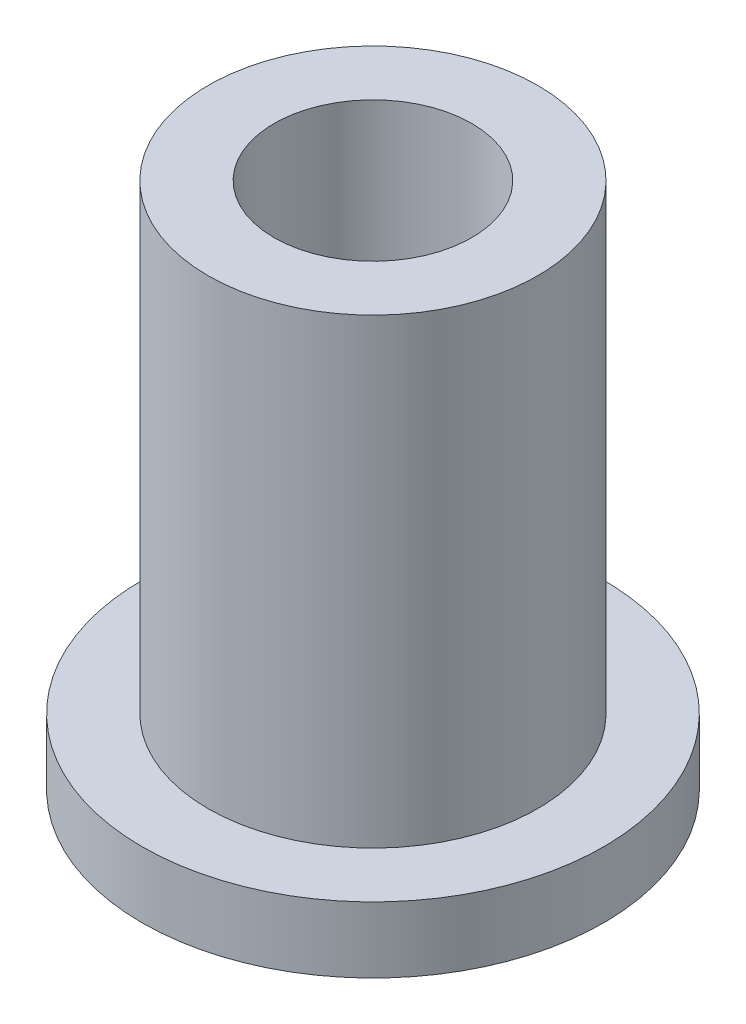
from build123d import *

# Parameters (mm, degrees)
SKETCH2_R           = 3.96875
SKETCH2_R_2         = 2.38125
BOSS_EXTRUDE1_DEPTH = 12.7
SKETCH3_R           = 5.55625
SKETCH3_R_2         = 3.96875
BOSS_EXTRUDE2_DEPTH = 1.5875


with BuildPart() as part:
    # Sketch2 → Boss-Extrude1 (new body)
    with BuildSketch(Plane(origin=(0, 0, 0), x_dir=(1, 0, 0), z_dir=(0, 1, 0))):
        Circle(SKETCH2_R)
        Circle(SKETCH2_R_2, mode=Mode.SUBTRACT)
    extrude(amount=BOSS_EXTRUDE1_DEPTH)

    # Sketch3 → Boss-Extrude2 (add)
    with BuildSketch(Plane(origin=(0, 0, 0), x_dir=(1, 0, 0), z_dir=(0, 1, 0))):
        Circle(SKETCH3_R)
        Circle(SKETCH3_R_2, mode=Mode.SUBTRACT)
    extrude(amount=BOSS_EXTRUDE2_DEPTH)


solid = part.part
